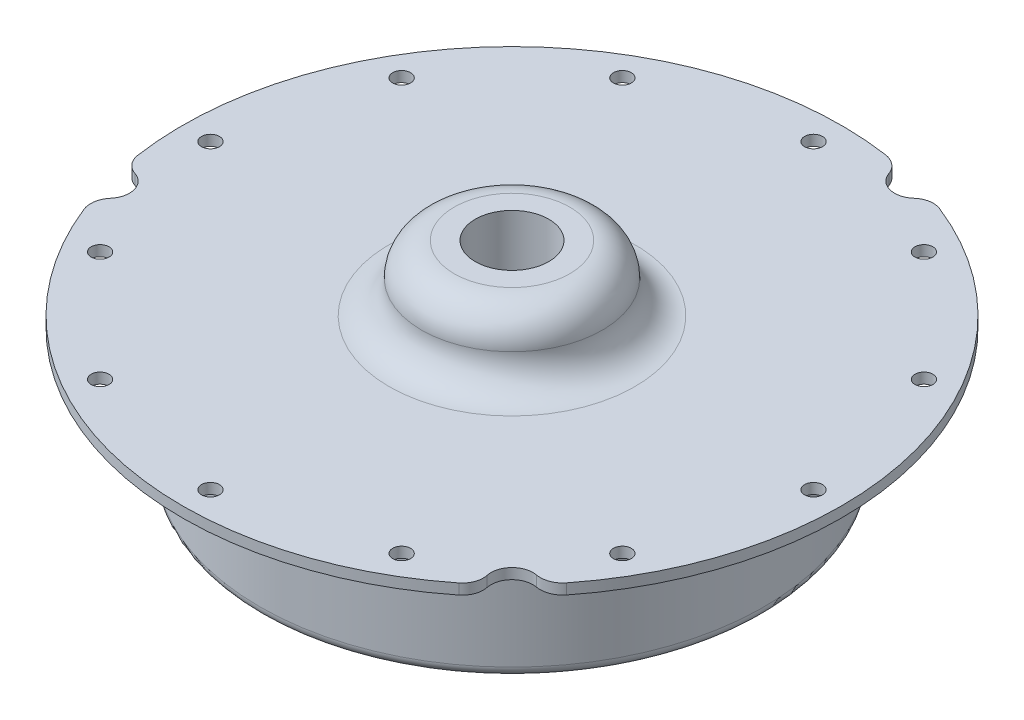
from build123d import *

# Parameters (mm, degrees)
F_36_0_1065_DIAMETER_HOLE1_D   = 2.7051
CIRPATTERN1_COUNT              = 12
F_7_16_0_4375_DIAMETER_HOLE1_D = 11.1125
CUT_EXTRUDE1_DEPTH             = 1.5875


with BuildPart() as part:
    # Sketch1 → Revolve1 (revolve)
    with BuildSketch(Plane.XY):
        with BuildLine():
            Line((-49.784, 0), (-39.6875, 0))
            ThreePointArc((-39.6875, 0), (-38.564967985, -0.464967985), (-38.1, -1.5875))
            Line((-38.1, -1.5875), (-38.1, -17.4625))
            ThreePointArc((-38.1, -17.4625), (-36.5125, -19.05), (-34.925, -17.4625))
            Line((-34.925, -17.4625), (-34.925, -3.175))
            ThreePointArc((-34.925, -3.175), (-33.99506403, -0.92993597), (-31.75, 0))
            Line((-31.75, 0), (-5.55625, 0))
            Line((-5.55625, 0), (-5.55625, 11.43))
            Line((-5.55625, 11.43), (-8.73125, 11.43))
            ThreePointArc((-8.73125, 11.43), (-12.211099247, 9.988599247), (-13.6525, 6.50875))
            ThreePointArc((-13.6525, 6.50875), (-15.093900753, 3.028900753), (-18.57375, 1.5875))
            Line((-18.57375, 1.5875), (-49.784, 1.5875))
            Line((-49.784, 1.5875), (-49.784, 0))
        make_face()
    revolve(axis=Axis((0, 55, 0), (0, -1, 0)))

    # #36 (0.1065) Diameter Hole1 (through all)
    with Locations(Plane(origin=(0, 1.5875, 0), x_dir=(1, 0, 0), z_dir=(0, 1, 0))):
        with Locations((-45.5549, 0)):
            f_36_0_1065_diameter_hole1 = Hole(F_36_0_1065_DIAMETER_HOLE1_D / 2)

    # CirPattern1: #36 (0.1065) Diameter Hole1 ×12 about axis
    cirpattern1_axis = Axis((0, 0, 0), (0, 1, 0))
    for i in range(1, CIRPATTERN1_COUNT):
        add(f_36_0_1065_diameter_hole1.rotate(cirpattern1_axis, i * 360 / CIRPATTERN1_COUNT), mode=Mode.SUBTRACT)

    # 7/16 (0.4375) Diameter Hole1 (through all)
    with Locations(Plane(origin=(0, 11.43, 0), x_dir=(1, 0, 0), z_dir=(0, 1, 0))):
        with Locations((0, 0)):
            Hole(F_7_16_0_4375_DIAMETER_HOLE1_D / 2)

    # Sketch6 → Cut-Extrude1 (cut)
    with BuildSketch(Plane(origin=(0, 1.5875, 0), x_dir=(1, 0, 0), z_dir=(0, 1, 0))):
        with BuildLine():
            ThreePointArc((-49.242879261, -7.320211614), (-48.530354217, -8.899238309), (-47.095020424, -9.869204363))
            ThreePointArc((-47.095020424, -9.869204363), (-45.030441175, -12.028256218), (-45.672293343, -14.945792538))
            ThreePointArc((-45.672293343, -14.945792538), (-46.444411893, -16.607589119), (-46.247219759, -18.429360287))
            ThreePointArc((-46.247219759, -18.429360287), (-48.067068235, -12.961620549), (-49.242879261, -7.320211614))
        make_face()
        with BuildLine():
            ThreePointArc((9.892710654, 47.026262554), (8.839611874, 48.525835123), (7.163315695, 49.265947309))
            ThreePointArc((7.163315695, 49.265947309), (12.808441449, 48.108112452), (18.281950412, 46.305690203))
            ThreePointArc((18.281950412, 46.305690203), (16.558210658, 46.478138761), (15.000528519, 45.72008626))
            ThreePointArc((15.000528519, 45.72008626), (12.09844514, 45.01163411), (9.892710654, 47.026262554))
        make_face()
        with BuildLine():
            ThreePointArc((35.77958269, -32.080470015), (37.604800019, -31.918246004), (39.083904064, -30.836587022))
            ThreePointArc((39.083904064, -30.836587022), (35.258626787, -35.146491903), (30.96092885, -38.985478588))
            ThreePointArc((30.96092885, -38.985478588), (31.972143558, -37.578900452), (32.094491905, -35.850881898))
            ThreePointArc((32.094491905, -35.850881898), (32.931996035, -32.983377892), (35.77958269, -32.080470015))
        make_face()
    extrude(amount=-CUT_EXTRUDE1_DEPTH, mode=Mode.SUBTRACT)


solid = part.part
